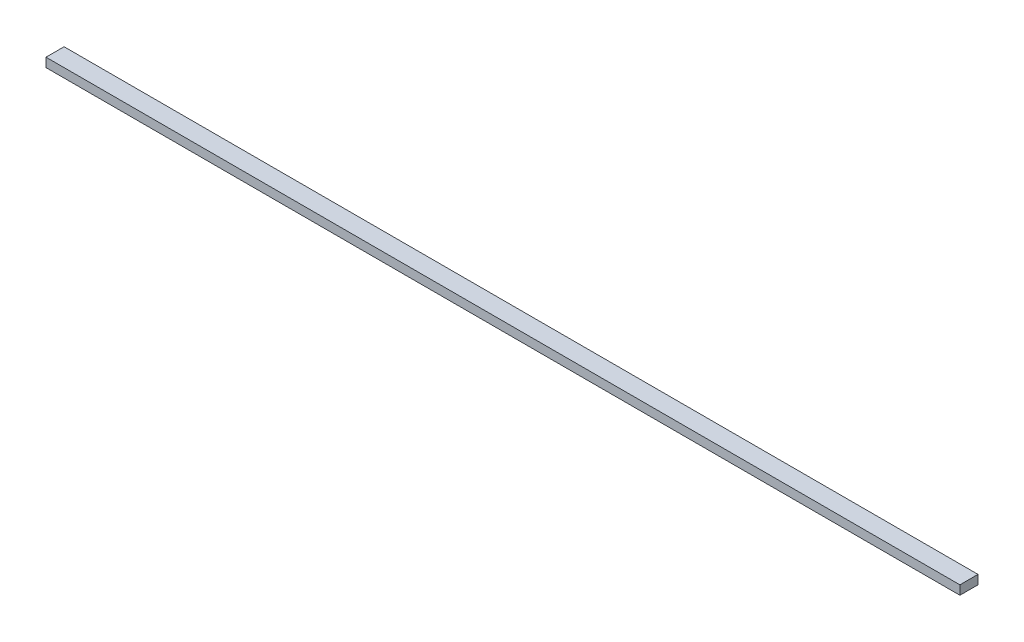
from build123d import *

# Parameters (mm, degrees)
SKETCH1_W           = 1010
SKETCH1_H           = 20
BOSS_EXTRUDE1_DEPTH = 10


with BuildPart() as part:
    # Sketch1 → Boss-Extrude1 (new body)
    with BuildSketch(Plane(origin=(0, 0, 0), x_dir=(1, 0, 0), z_dir=(0, 1, 0))):
        Rectangle(SKETCH1_W, SKETCH1_H)
    extrude(amount=BOSS_EXTRUDE1_DEPTH)


solid = part.part
